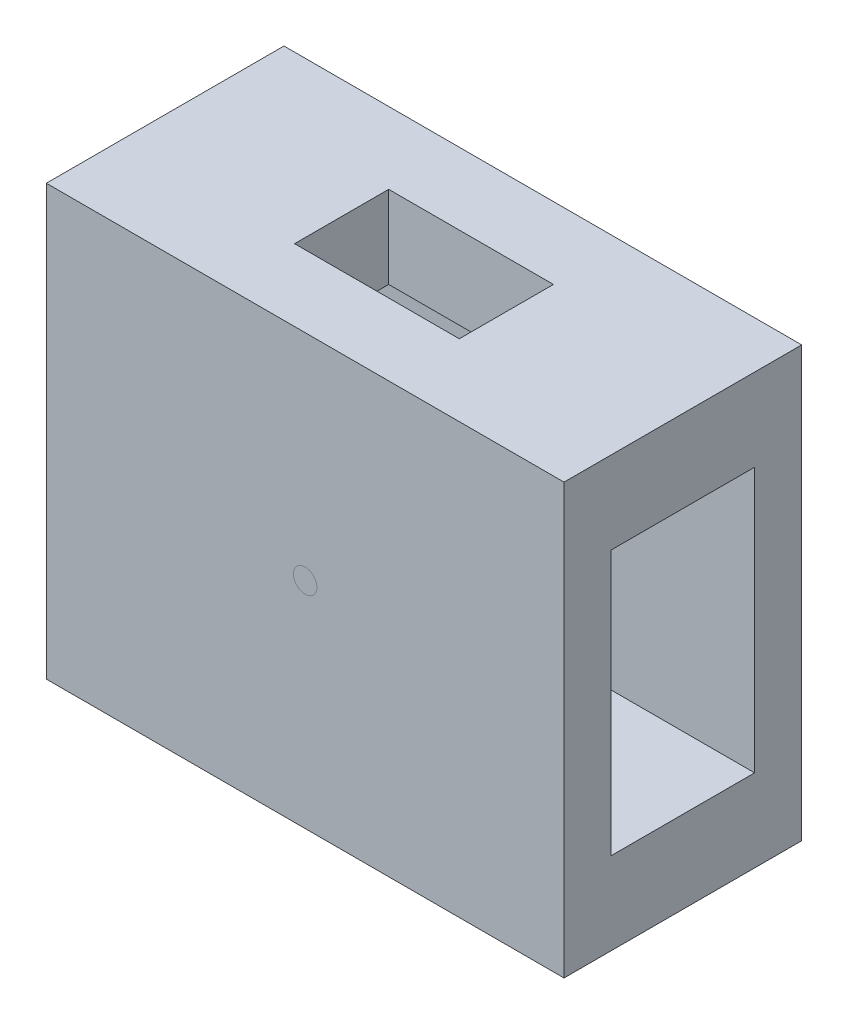
from build123d import *

# Parameters (mm, degrees)
SKETCH1_W           = 20.2
SKETCH1_H           = 36.5
SKETCH1_W_2         = 12.2
SKETCH1_H_2         = 22.5
BOSS_EXTRUDE1_DEPTH = 22
SKETCH3_R           = 1
CUT_EXTRUDE2_DEPTH  = 0.0001
SKETCH6_W           = 14
SKETCH6_H           = 8
CUT_EXTRUDE3_DEPTH  = 25


with BuildPart() as part:
    # Sketch1 → Boss-Extrude1 (new body, symmetric)
    with BuildSketch(Plane(origin=(0, 0, 0), x_dir=(0, 0, -1), z_dir=(1, 0, 0))):
        Rectangle(SKETCH1_W, SKETCH1_H)
        Rectangle(SKETCH1_W_2, SKETCH1_H_2, mode=Mode.SUBTRACT)
    extrude(amount=BOSS_EXTRUDE1_DEPTH, both=True)

    # Sketch3 → Cut-Extrude2 (cut)
    with BuildSketch(Plane.XY.offset(10.1)):
        Circle(SKETCH3_R)
    extrude(amount=-CUT_EXTRUDE2_DEPTH, mode=Mode.SUBTRACT)

    # Sketch6 → Cut-Extrude3 (cut, symmetric)
    with BuildSketch(Plane(origin=(0, 0, 0), x_dir=(1, 0, 0), z_dir=(0, 1, 0))):
        Rectangle(SKETCH6_W, SKETCH6_H)
    extrude(amount=CUT_EXTRUDE3_DEPTH, both=True, mode=Mode.SUBTRACT)


solid = part.part
